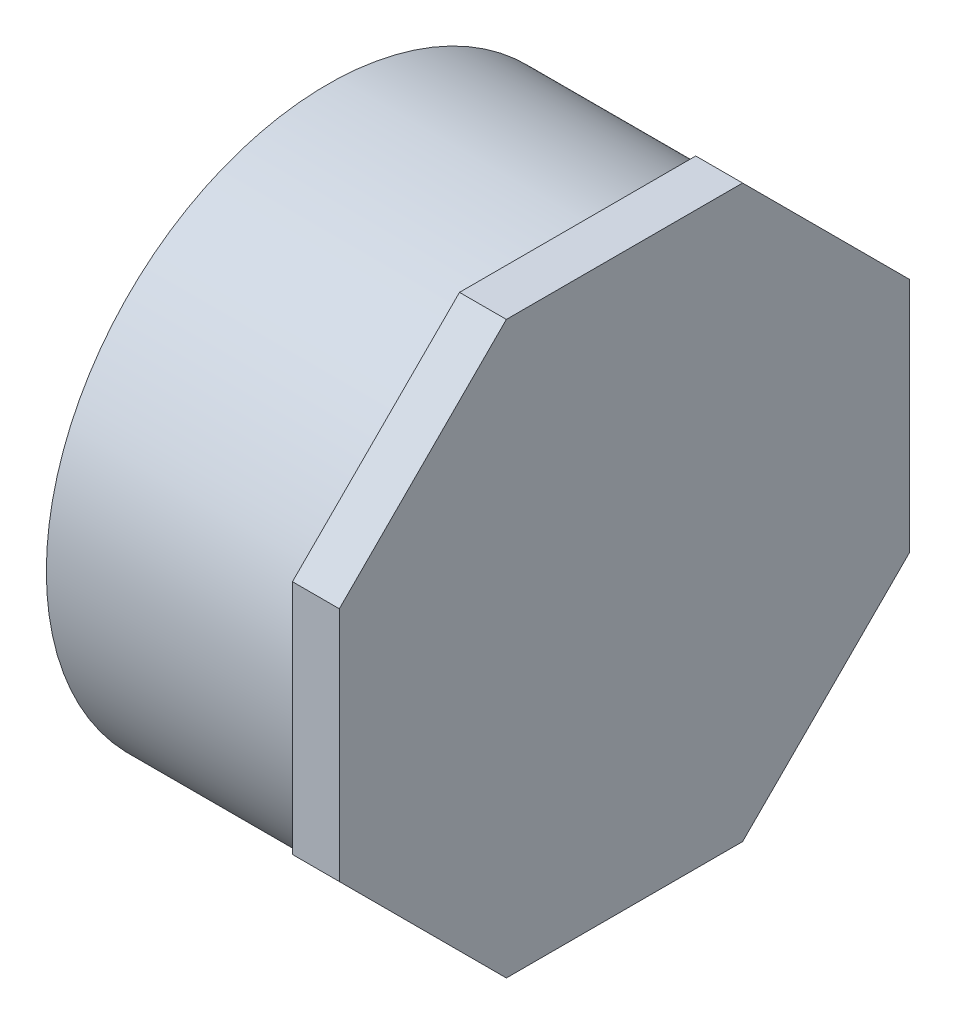
from build123d import *

# Parameters (mm, degrees)
SKETCH2_R           = 57.15
BOSS_EXTRUDE1_DEPTH = 9.525


with BuildPart() as part:
    # Sketch1 → Revolve1 (revolve)
    with BuildSketch(Plane.XY):
        Polygon((-30.1625, -57.15), (30.1625, -57.15), (30.1625, 0), (20.6375, 0), (20.6375, -51.1302), (-30.1625, -51.1302), align=None)
    revolve(axis=Axis((-30.1625, 0, 0), (1, 0, 0)))

    # Sketch2 → Boss-Extrude1 (add)
    with BuildSketch(Plane(origin=(30.1625, 0, 0), x_dir=(0, 0, -1), z_dir=(1, 0, 0))):
        Polygon((-24.001087105, 57.94375), (-57.94375, 24.001087105), (-57.94375, -24.001087105), (-24.001087105, -57.94375), (24.001087105, -57.94375), (57.94375, -24.001087105), (57.94375, 24.001087105), (24.001087105, 57.94375), align=None)
        Circle(SKETCH2_R, mode=Mode.SUBTRACT)
    extrude(amount=-BOSS_EXTRUDE1_DEPTH)


solid = part.part
